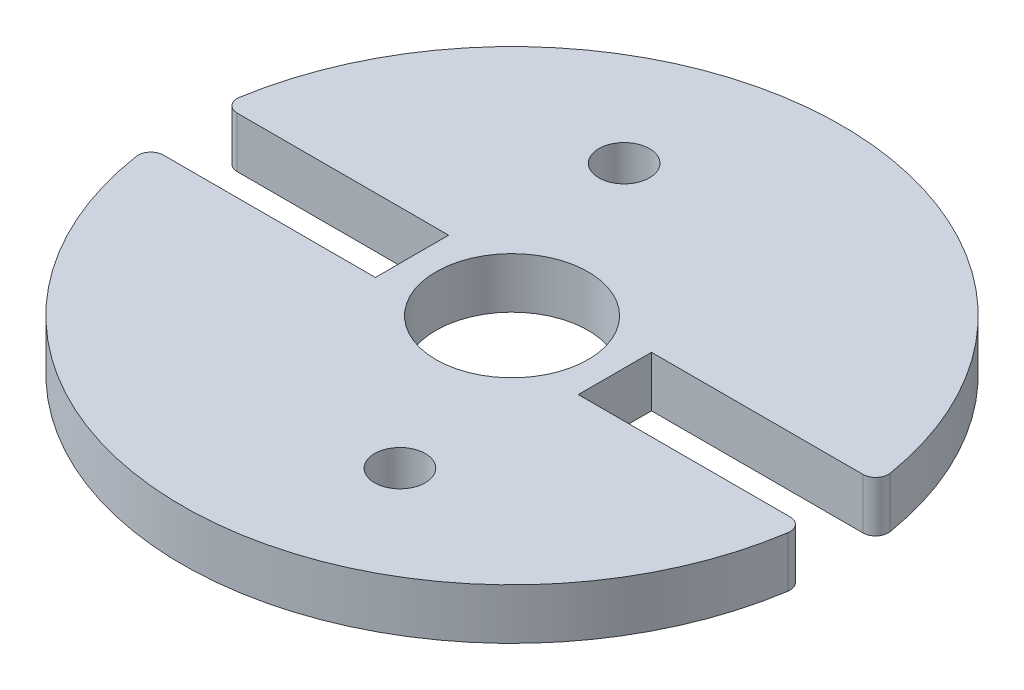
from build123d import *

# Parameters (mm, degrees)
SKETCH1_R           = 1
SKETCH1_R_2         = 3
BOSS_EXTRUDE1_DEPTH = 2


with BuildPart() as part:
    # Sketch1 → Boss-Extrude1 (new body)
    with BuildSketch(Plane(origin=(0, 0, 0), x_dir=(1, 0, 0), z_dir=(0, 1, 0))):
        with BuildLine():
            Line((-12.338962679, 1.5), (-4, 1.5))
            Line((-4, 1.5), (-4, -1.388047838))
            Line((-4, -1.388047838), (-12.356588338, -1.388047838))
            ThreePointArc((-12.356588338, -1.388047838), (-12.735904141, -1.562287924), (-12.850851872, -1.963569752))
            ThreePointArc((-12.850851872, -1.963569752), (0, -13), (12.850851872, -1.963569752))
            ThreePointArc((12.850851872, -1.963569752), (12.735904141, -1.562287924), (12.356588338, -1.388047838))
            Line((12.356588338, -1.388047838), (4, -1.388047838))
            Line((4, -1.388047838), (4, 1.5))
            Line((4, 1.5), (12.338962679, 1.5))
            ThreePointArc((12.338962679, 1.5), (12.719751335, 1.675962965), (12.832521186, 2.08))
            ThreePointArc((12.832521186, 2.08), (0, 13), (-12.832521186, 2.08))
            ThreePointArc((-12.832521186, 2.08), (-12.719751335, 1.675962965), (-12.338962679, 1.5))
        make_face()
        with Locations((-2.996852747, 7.417470837)):
            Circle(SKETCH1_R, mode=Mode.SUBTRACT)
        with Locations((2.996852747, -7.417470837)):
            Circle(SKETCH1_R, mode=Mode.SUBTRACT)
        Circle(SKETCH1_R_2, mode=Mode.SUBTRACT)
    extrude(amount=BOSS_EXTRUDE1_DEPTH)


solid = part.part
